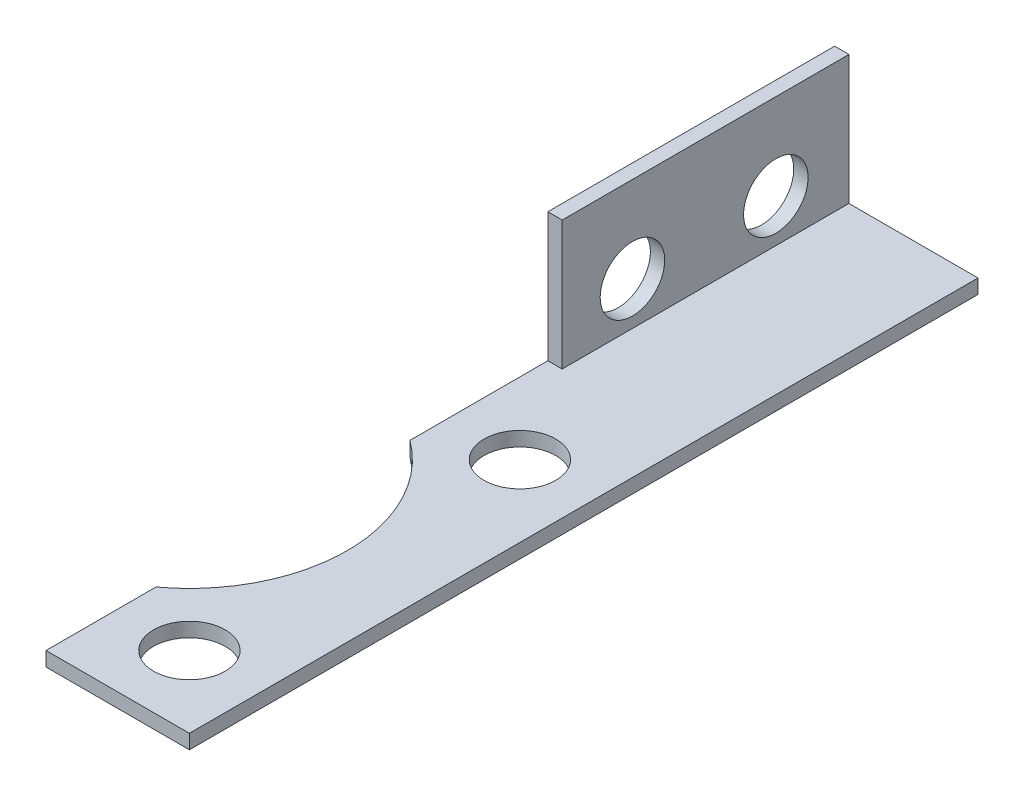
from build123d import *

# Parameters (mm, degrees)
BOSS_EXTRUDE1_DEPTH = 55
SKETCH2_R           = 2.5
CUT_EXTRUDE1_DEPTH  = 2
SKETCH3_W           = 1
SKETCH3_H           = 9
CUT_EXTRUDE2_DEPTH  = 35
SKETCH4_R           = 2.25
CUT_EXTRUDE3_DEPTH  = 11


with BuildPart() as part:
    # Sketch1 → Boss-Extrude1 (new body)
    with BuildSketch(Plane.XY):
        Polygon((0, 10), (0, 0), (10, 0), (10, 1), (1, 1), (1, 10), align=None)
    extrude(amount=BOSS_EXTRUDE1_DEPTH)

    # Sketch2 → Cut-Extrude1 (cut, through all)
    with BuildSketch(Plane(origin=(0, 1, 0), x_dir=(1, 0, 0), z_dir=(0, 1, 0))):
        with Locations((5, -50)):
            Circle(SKETCH2_R)
        with Locations((5, -26.95)):
            Circle(SKETCH2_R)
        with BuildLine():
            Line((-2.7555139, -28.141028133), (-2.7555139, -48.808971867))
            ThreePointArc((-2.7555139, -48.808971867), (4.475, -38.475), (-2.7555139, -28.141028133))
        make_face()
    extrude(amount=-CUT_EXTRUDE1_DEPTH, mode=Mode.SUBTRACT)

    # Sketch3 → Cut-Extrude2 (cut)
    with BuildSketch(Plane.XY.offset(55)):
        with Locations((0.5, 5.5)):
            Rectangle(SKETCH3_W, SKETCH3_H)
    extrude(amount=-CUT_EXTRUDE2_DEPTH, mode=Mode.SUBTRACT)

    # Sketch4 → Cut-Extrude3 (cut, through all)
    with BuildSketch(Plane.ZY):
        with Locations((5.1, 4)):
            Circle(SKETCH4_R)
        with Locations((15.1, 4)):
            Circle(SKETCH4_R)
    extrude(amount=-CUT_EXTRUDE3_DEPTH, mode=Mode.SUBTRACT)


solid = part.part
